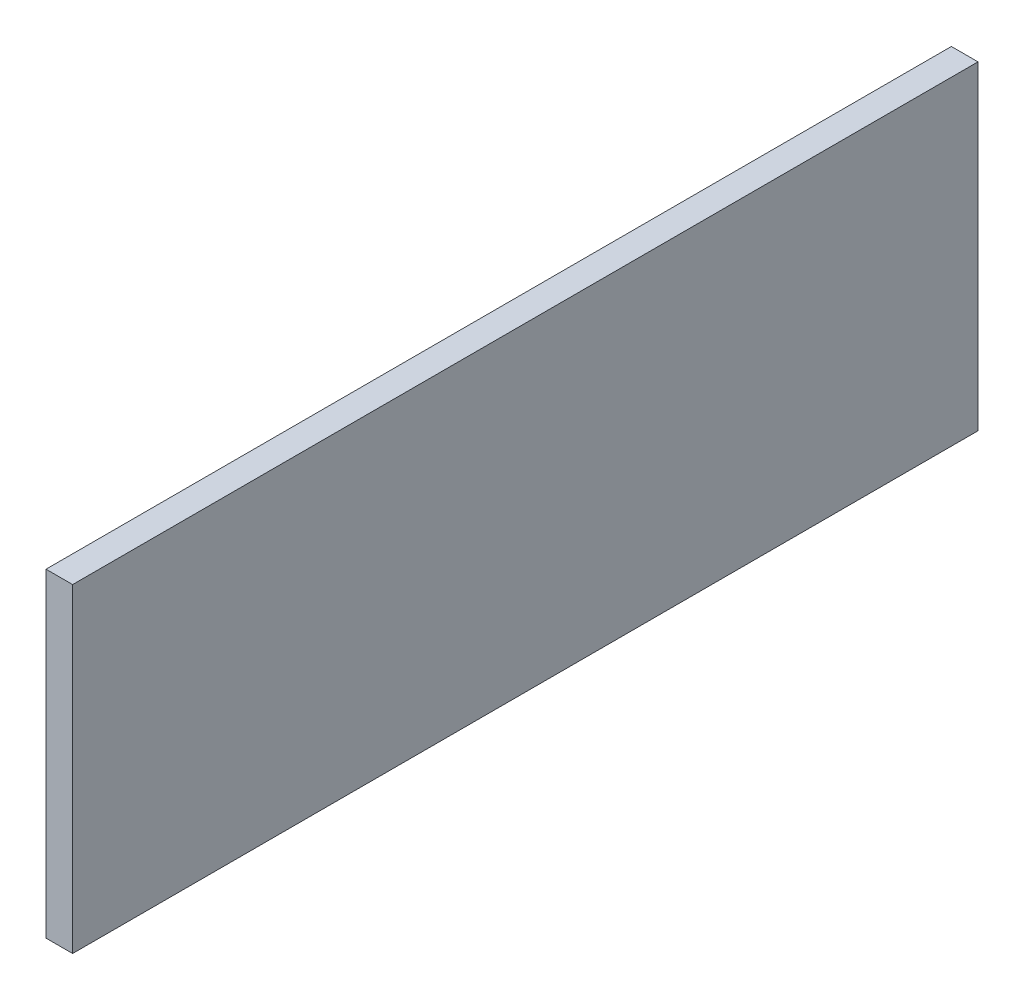
from build123d import *

# Parameters (mm, degrees)
SKETCH1_W           = 647.7
SKETCH1_H           = 228.6
BOSS_EXTRUDE1_DEPTH = 19.05


with BuildPart() as part:
    # Sketch1 → Boss-Extrude1 (new body)
    with BuildSketch(Plane(origin=(0, 0, 0), x_dir=(0, 0, -1), z_dir=(1, 0, 0))):
        with Locations((323.85, -114.3)):
            Rectangle(SKETCH1_W, SKETCH1_H)
    extrude(amount=BOSS_EXTRUDE1_DEPTH)


solid = part.part
